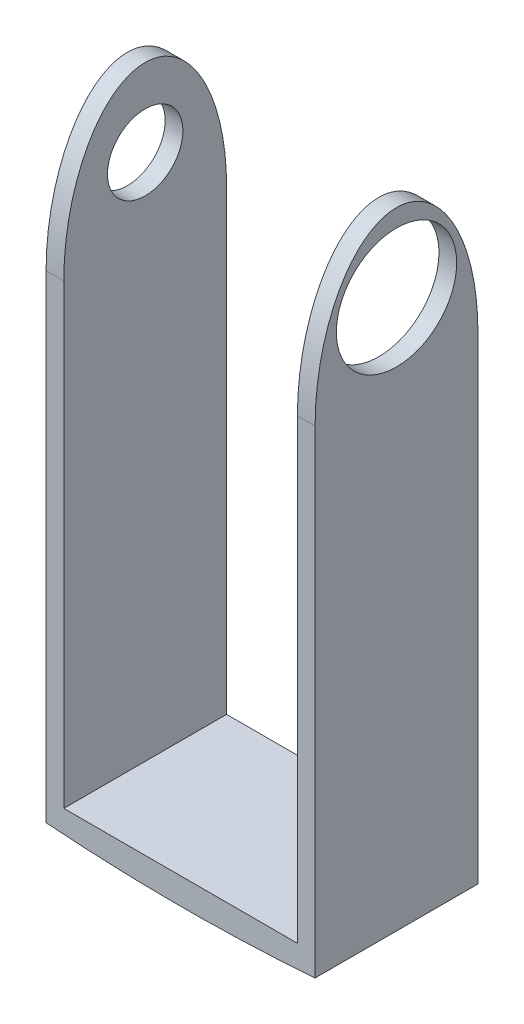
from build123d import *

# Parameters (mm, degrees)
BOSS_EXTRUDE1_DEPTH       = 5.842
F_6_32_TAPPED_HOLE1_D     = 2.7051
F_6_32_TAPPED_HOLE1_DEPTH = 0.635
CUT_EXTRUDE1_REACH        = 11.652
SKETCH6_R                 = 2.159
BOSS_EXTRUDE2_DEPTH       = 5.842
CUT_EXTRUDE4_DEPTH        = 10.652


with BuildPart() as part:
    # Sketch1 → Boss-Extrude1 (new body)
    with BuildSketch(Plane.XY):
        Polygon((-3.353873239, 20.18718662), (-3.353873239, -2.29181338), (6.298126761, -2.29181338), (6.298126761, 20.18718662), (5.663126761, 20.18718662), (5.663126761, -1.52981338), (-2.718873239, -1.52981338), (-2.718873239, 20.18718662), align=None)
    extrude(amount=BOSS_EXTRUDE1_DEPTH)

    # #6-32 Tapped Hole1
    with Locations(Plane.ZY.offset(3.353873239)):
        with Locations((2.921, 17.39318662)):
            Hole(F_6_32_TAPPED_HOLE1_D / 2, depth=F_6_32_TAPPED_HOLE1_DEPTH)

    # Sketch6 → Cut-Extrude1 (cut, up to next)
    with BuildSketch(Plane(origin=(6.298126761, 0, 0), x_dir=(0, 0, -1), z_dir=(1, 0, 0)), mode=Mode.PRIVATE) as cut_extrude1_sk1:
        with Locations((-2.921, 17.39318662)):
            Circle(SKETCH6_R)
    cut_extrude1_tool1 = extrude(cut_extrude1_sk1.sketch, amount=-CUT_EXTRUDE1_REACH, mode=Mode.PRIVATE) & part.part
    add(cut_extrude1_tool1.solids().sort_by_distance((6.298127, 17.393187, 2.921))[0], mode=Mode.SUBTRACT)

    # Sketch15 → Boss-Extrude2 (add, through all)
    with BuildSketch(Plane.XY):
        with BuildLine():
            Line((6.298126761, -2.29181338), (-3.353873239, -2.29181338))
            ThreePointArc((-3.353873239, -2.29181338), (1.472126761, -2.477704159), (6.298126761, -2.29181338))
        make_face()
    extrude(amount=BOSS_EXTRUDE2_DEPTH)

    # Sketch28 → Cut-Extrude4 (cut, through all)
    with BuildSketch(Plane(origin=(6.298126761, 0, 0), x_dir=(0, 0, -1), z_dir=(1, 0, 0))):
        with BuildLine():
            Line((-5.842, 20.18718662), (-5.842, 14.860557672))
            add(Edge.make_bspline(
                [(-2.921, 20.18718662), (-5.842, 20.18718662), (-5.842, 14.860557672)],
                knots=[6.283185307, 6.283185307, 6.283185307, 7.853981634, 7.853981634, 7.853981634], degree=2, weights=[1, 0.707106781, 1]))
            Line((-2.920999983, 20.18718662), (-5.842, 20.18718662))
        make_face()
        with BuildLine():
            Line((0, 20.18718662), (-2.920999983, 20.18718662))
            add(Edge.make_bspline(
                [(0, 14.860557672), (0, 20.18718662), (-2.921, 20.18718662)],
                knots=[4.71238898, 4.71238898, 4.71238898, 6.283185307, 6.283185307, 6.283185307], degree=2, weights=[1, 0.707106781, 1]))
            Line((0, 14.860557672), (0, 20.18718662))
        make_face()
    extrude(amount=-CUT_EXTRUDE4_DEPTH, mode=Mode.SUBTRACT)


solid = part.part
